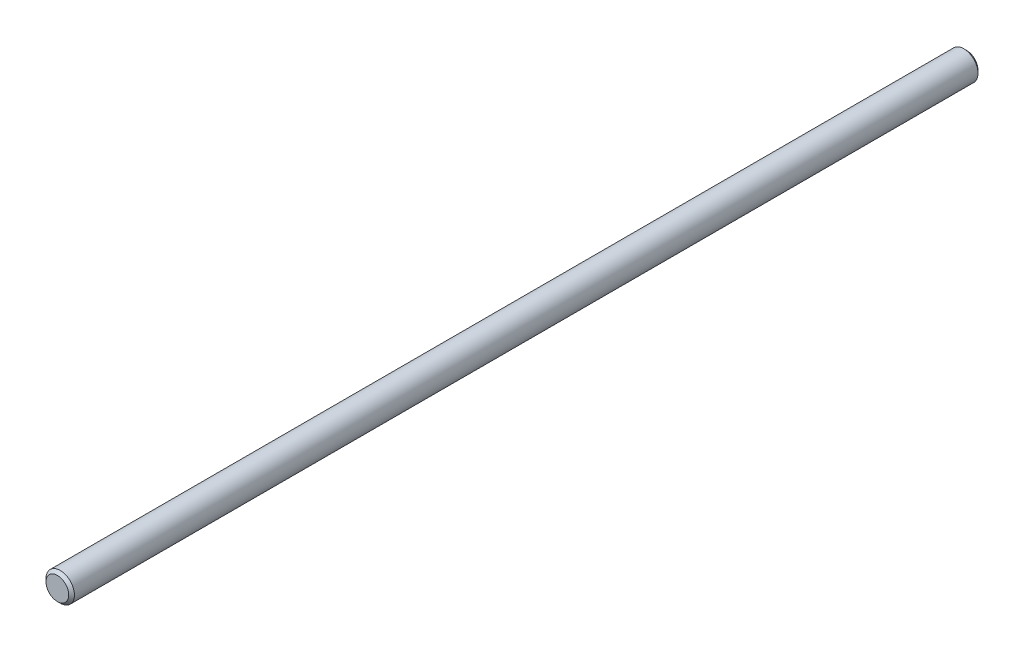
from build123d import *

# Parameters (mm, degrees)
SKETCH3_R           = 4.7625
BOSS_EXTRUDE1_DEPTH = 152.4
CHAMFER1_SIZE       = 0.9525


with BuildPart() as part:
    # Sketch3 → Boss-Extrude1 (new body, symmetric)
    with BuildSketch(Plane.XY):
        Circle(SKETCH3_R)
    extrude(amount=BOSS_EXTRUDE1_DEPTH, both=True)

    # Chamfer1
    chamfer1_edges = [part.edges().sort_by_distance(p)[0] for p in [
        (-4.7625, 0, -152.4),
        (-4.7625, 0, 152.4),
    ]]
    chamfer(chamfer1_edges, length=CHAMFER1_SIZE)


solid = part.part
